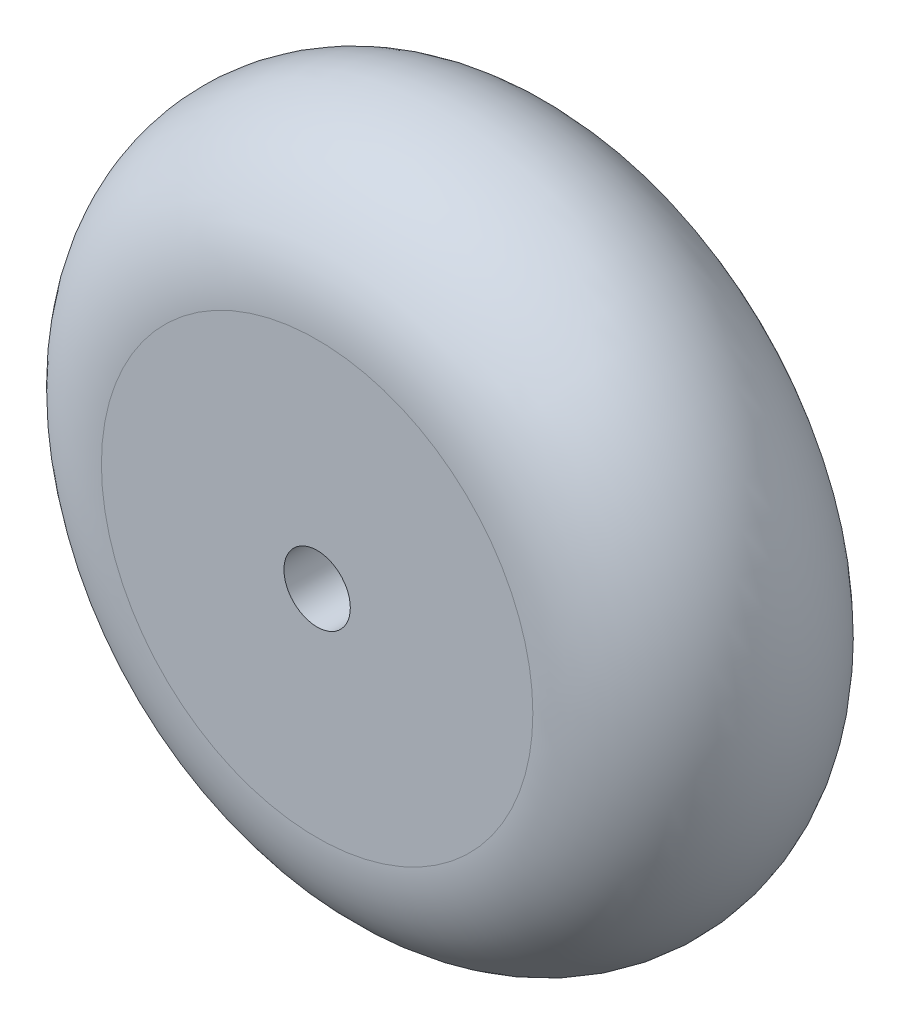
from build123d import *

# Parameters (mm, degrees)
SKETCH_2_R               = 19.5
EXTRUDE_1_DEPTH          = 24
CUT_EXTRUDE_1_DEPTH      = 51.601383505
CUT_EXTRUDE_1_DEPTH_BACK = 51.601383505
SKETCH_5_R               = 3


with BuildPart() as part:
    # 草图2 → 凸台-拉伸1 (new body)
    with BuildSketch(Plane.XY):
        Circle(SKETCH_2_R)
    extrude(amount=EXTRUDE_1_DEPTH)

    # 草图5 → 切除-拉伸1 (cut, two sides: drawn at the far end of the back side and taken through both)
    with BuildSketch(Plane.XY.offset(24).offset(-CUT_EXTRUDE_1_DEPTH_BACK)):
        Circle(SKETCH_5_R)
    extrude(amount=CUT_EXTRUDE_1_DEPTH + CUT_EXTRUDE_1_DEPTH_BACK, mode=Mode.SUBTRACT)


with BuildPart() as body_2:
    # 草图4 → 旋转1 (revolve)
    with BuildSketch(Plane(origin=(0, 0, 0), x_dir=(0, 0, -1), z_dir=(1, 0, 0))):
        with BuildLine():
            Line((-24, 19.5), (0, 19.5))
            ThreePointArc((0, 19.5), (-12, 31.5), (-24, 19.5))
        make_face()
    revolve(axis=Axis((0, 0, 38.27366172), (0, 0, -1)))


solid = Compound([part.part, body_2.part])
